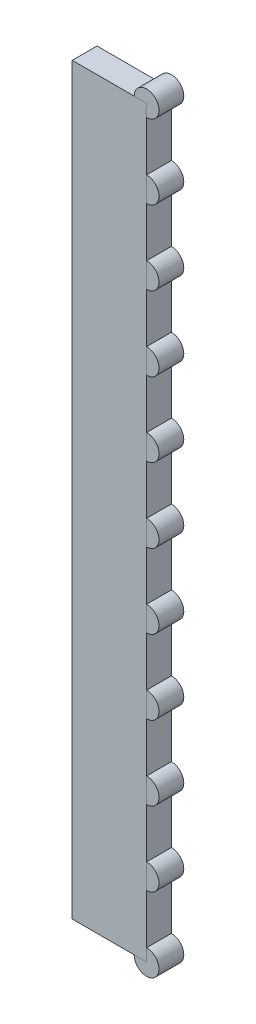
from build123d import *

# Parameters (mm, degrees)
SKETCH2_W              = 30
SKETCH2_H              = 300
BOSS_EXTRUDE1_DEPTH    = 10
SKETCH3_R              = 5
BOSS_EXTRUDE2_DEPTH    = 10
BOSS_EXTRUDE2_2_DEPTH  = 10
BOSS_EXTRUDE2_3_DEPTH  = 10
BOSS_EXTRUDE2_4_DEPTH  = 10
BOSS_EXTRUDE2_5_DEPTH  = 10
BOSS_EXTRUDE2_6_DEPTH  = 10
BOSS_EXTRUDE2_7_DEPTH  = 10
BOSS_EXTRUDE2_8_DEPTH  = 10
BOSS_EXTRUDE2_9_DEPTH  = 10
BOSS_EXTRUDE2_10_DEPTH = 10
BOSS_EXTRUDE2_11_DEPTH = 10


with BuildPart() as part:
    # Sketch2 → Boss-Extrude1 (new body)
    with BuildSketch(Plane.XY):
        with Locations((15, 150)):
            Rectangle(SKETCH2_W, SKETCH2_H)
    extrude(amount=BOSS_EXTRUDE1_DEPTH)


with BuildPart() as body_2:
    # Sketch3 → Boss-Extrude2 (new body)
    with BuildSketch(Plane.XY.offset(10)):
        with Locations((30, 300)):
            Circle(SKETCH3_R)
    extrude(amount=-BOSS_EXTRUDE2_DEPTH)


with BuildPart() as body_3:
    # Sketch3 → Boss-Extrude2 2 (new body)
    with BuildSketch(Plane.XY.offset(10)):
        with Locations((30, 270)):
            Circle(SKETCH3_R)
    extrude(amount=-BOSS_EXTRUDE2_2_DEPTH)


with BuildPart() as body_4:
    # Sketch3 → Boss-Extrude2 3 (new body)
    with BuildSketch(Plane.XY.offset(10)):
        with Locations((30, 240)):
            Circle(SKETCH3_R)
    extrude(amount=-BOSS_EXTRUDE2_3_DEPTH)


with BuildPart() as body_5:
    # Sketch3 → Boss-Extrude2 4 (new body)
    with BuildSketch(Plane.XY.offset(10)):
        with Locations((30, 210)):
            Circle(SKETCH3_R)
    extrude(amount=-BOSS_EXTRUDE2_4_DEPTH)


with BuildPart() as body_6:
    # Sketch3 → Boss-Extrude2 5 (new body)
    with BuildSketch(Plane.XY.offset(10)):
        with Locations((30, 180)):
            Circle(SKETCH3_R)
    extrude(amount=-BOSS_EXTRUDE2_5_DEPTH)


with BuildPart() as body_7:
    # Sketch3 → Boss-Extrude2 6 (new body)
    with BuildSketch(Plane.XY.offset(10)):
        with Locations((30, 150)):
            Circle(SKETCH3_R)
    extrude(amount=-BOSS_EXTRUDE2_6_DEPTH)


with BuildPart() as body_8:
    # Sketch3 → Boss-Extrude2 7 (new body)
    with BuildSketch(Plane.XY.offset(10)):
        with Locations((30, 120)):
            Circle(SKETCH3_R)
    extrude(amount=-BOSS_EXTRUDE2_7_DEPTH)


with BuildPart() as body_9:
    # Sketch3 → Boss-Extrude2 8 (new body)
    with BuildSketch(Plane.XY.offset(10)):
        with Locations((30, 90)):
            Circle(SKETCH3_R)
    extrude(amount=-BOSS_EXTRUDE2_8_DEPTH)


with BuildPart() as body_10:
    # Sketch3 → Boss-Extrude2 9 (new body)
    with BuildSketch(Plane.XY.offset(10)):
        with Locations((30, 60)):
            Circle(SKETCH3_R)
    extrude(amount=-BOSS_EXTRUDE2_9_DEPTH)


with BuildPart() as body_11:
    # Sketch3 → Boss-Extrude2 10 (new body)
    with BuildSketch(Plane.XY.offset(10)):
        with Locations((30, 30)):
            Circle(SKETCH3_R)
    extrude(amount=-BOSS_EXTRUDE2_10_DEPTH)


with BuildPart() as body_12:
    # Sketch3 → Boss-Extrude2 11 (new body)
    with BuildSketch(Plane.XY.offset(10)):
        with Locations((30, 0)):
            Circle(SKETCH3_R)
    extrude(amount=-BOSS_EXTRUDE2_11_DEPTH)


solid = Compound([part.part, body_2.part, body_3.part, body_4.part, body_5.part, body_6.part, body_7.part, body_8.part, body_9.part, body_10.part, body_11.part, body_12.part])
